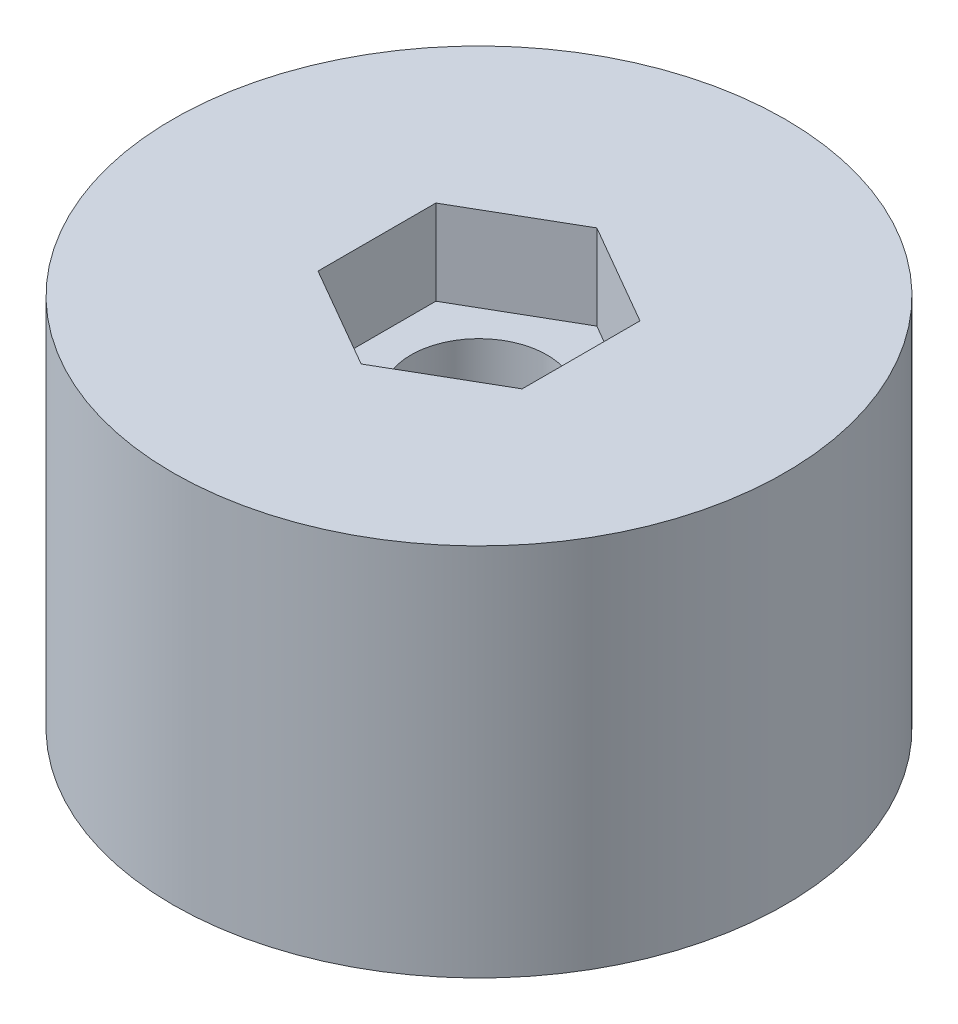
from build123d import *

# Parameters (mm, degrees)
SKETCH1_R           = 9
BOSS_EXTRUDE1_DEPTH = 11
CUT_EXTRUDE1_REACH  = 13
SKETCH2_R           = 2
CUT_EXTRUDE2_DEPTH  = 2.5


with BuildPart() as part:
    # Sketch1 → Boss-Extrude1 (new body)
    with BuildSketch(Plane(origin=(0, 0, 0), x_dir=(1, 0, 0), z_dir=(0, 1, 0))):
        Circle(SKETCH1_R)
    extrude(amount=BOSS_EXTRUDE1_DEPTH)

    # Sketch2 → Cut-Extrude1 (cut, up to next)
    with BuildSketch(Plane(origin=(0, 11, 0), x_dir=(1, 0, 0), z_dir=(0, 1, 0)), mode=Mode.PRIVATE) as cut_extrude1_sk1:
        Circle(SKETCH2_R)
    cut_extrude1_tool1 = extrude(cut_extrude1_sk1.sketch, amount=-CUT_EXTRUDE1_REACH, mode=Mode.PRIVATE) & part.part
    add(cut_extrude1_tool1.solids().sort_by_distance((0, 11, 0))[0], mode=Mode.SUBTRACT)

    # Sketch3 → Cut-Extrude2 (cut)
    with BuildSketch(Plane(origin=(0, 11, 0), x_dir=(1, 0, 0), z_dir=(0, 1, 0))):
        Polygon((3, -1.732050808), (3, 1.732050808), (0, 3.464101615), (-3, 1.732050808), (-3, -1.732050808), (0, -3.464101615), align=None)
    extrude(amount=-CUT_EXTRUDE2_DEPTH, mode=Mode.SUBTRACT)


solid = part.part
